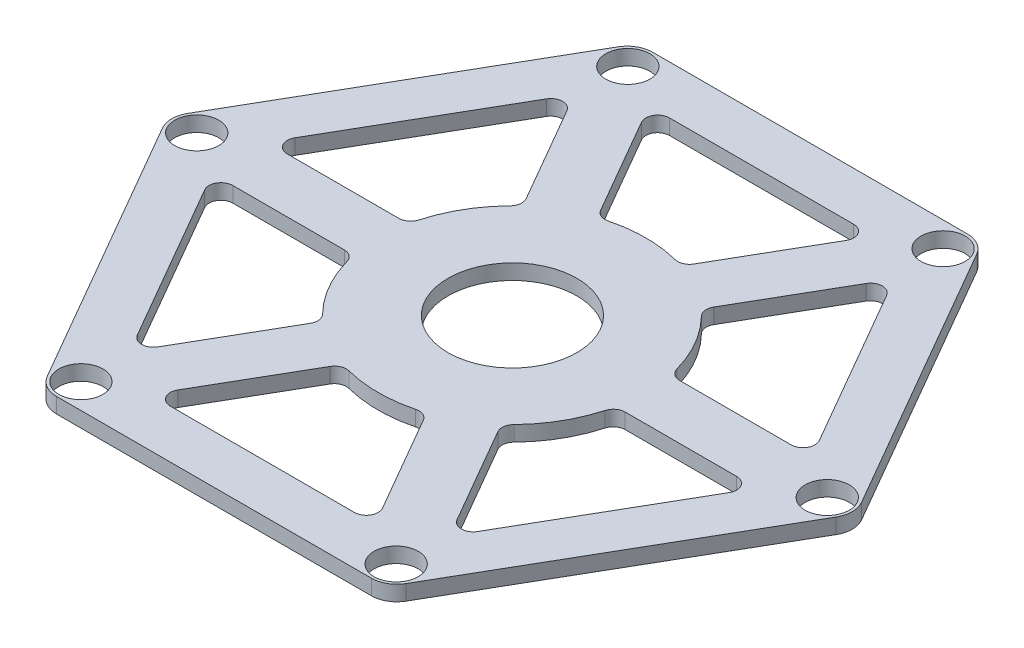
from build123d import *

# Parameters (mm, degrees)
SKETCH1_R           = 2.6
SKETCH1_R_2         = 7.6
BOSS_EXTRUDE1_DEPTH = 1.8
FILLET1_R           = 3
FILLET2_R           = 1.4
SCALE1_SCALE        = 1.15


with BuildPart() as part:
    # Sketch1 → Boss-Extrude1 (new body)
    with BuildSketch(Plane(origin=(0, 0, 0), x_dir=(1, 0, 0), z_dir=(0, 1, 0))):
        Polygon((20.3, 35.160631394), (-20.3, 35.160631394), (-40.6, 0), (-20.3, -35.160631394), (20.3, -35.160631394), (40.6, 0), align=None)
        with Locations((-18.636201283, -32.21652123)):
            Circle(SKETCH1_R, mode=Mode.SUBTRACT)
        with Locations((18.582225165, -32.247684356)):
            Circle(SKETCH1_R, mode=Mode.SUBTRACT)
        with Locations((37.218426448, -0.031163126)):
            Circle(SKETCH1_R, mode=Mode.SUBTRACT)
        with Locations((-37.218426448, 0.031163126)):
            Circle(SKETCH1_R, mode=Mode.SUBTRACT)
        with BuildLine():
            Line((-32.142053523, 3.218057696), (-18.857946477, 26.226806032))
            Line((-18.857946477, 26.226806032), (-10.521325069, 11.78735419))
            ThreePointArc((-10.521325069, 11.78735419), (-13.68320138, 7.9), (-15.468810706, 3.218057696))
            Line((-15.468810706, 3.218057696), (-32.142053523, 3.218057696))
        make_face(mode=Mode.SUBTRACT)
        with BuildLine():
            Line((-18.857946477, -26.226806032), (-32.142053523, -3.218057696))
            Line((-32.142053523, -3.218057696), (-15.468810706, -3.218057696))
            ThreePointArc((-15.468810706, -3.218057696), (-13.68320138, -7.9), (-10.521325069, -11.78735419))
            Line((-10.521325069, -11.78735419), (-18.857946477, -26.226806032))
        make_face(mode=Mode.SUBTRACT)
        with BuildLine():
            Line((13.284107046, -29.444863729), (-13.284107046, -29.444863729))
            Line((-13.284107046, -29.444863729), (-4.947485637, -15.005411886))
            ThreePointArc((-4.947485637, -15.005411886), (0, -15.8), (4.947485637, -15.005411886))
            Line((4.947485637, -15.005411886), (13.284107046, -29.444863729))
        make_face(mode=Mode.SUBTRACT)
        with BuildLine():
            Line((32.142053523, -3.218057696), (18.857946477, -26.226806032))
            Line((18.857946477, -26.226806032), (10.521325069, -11.78735419))
            ThreePointArc((10.521325069, -11.78735419), (13.68320138, -7.9), (15.468810706, -3.218057696))
            Line((15.468810706, -3.218057696), (32.142053523, -3.218057696))
        make_face(mode=Mode.SUBTRACT)
        with BuildLine():
            Line((18.857946477, 26.226806032), (32.142053523, 3.218057696))
            Line((32.142053523, 3.218057696), (15.468810706, 3.218057696))
            ThreePointArc((15.468810706, 3.218057696), (13.68320138, 7.9), (10.521325069, 11.78735419))
            Line((10.521325069, 11.78735419), (18.857946477, 26.226806032))
        make_face(mode=Mode.SUBTRACT)
        with BuildLine():
            Line((-13.284107046, 29.444863729), (13.284107046, 29.444863729))
            Line((13.284107046, 29.444863729), (4.947485637, 15.005411886))
            ThreePointArc((4.947485637, 15.005411886), (0, 15.8), (-4.947485637, 15.005411886))
            Line((-4.947485637, 15.005411886), (-13.284107046, 29.444863729))
        make_face(mode=Mode.SUBTRACT)
        with Locations((-18.582225165, 32.247684356)):
            Circle(SKETCH1_R, mode=Mode.SUBTRACT)
        with Locations((18.636201283, 32.21652123)):
            Circle(SKETCH1_R, mode=Mode.SUBTRACT)
        with Locations((0.052857117, 0)):
            Circle(SKETCH1_R_2, mode=Mode.SUBTRACT)
    extrude(amount=BOSS_EXTRUDE1_DEPTH)

    # Fillet1
    fillet1_edges = [part.edges().sort_by_distance(p)[0] for p in [
        (40.6, 0.9, 0),
        (20.3, 0.9, 35.160631394),
        (-20.3, 0.9, 35.160631394),
        (-40.6, 0.9, 0),
        (-20.3, 0.9, -35.160631394),
        (20.3, 0.9, -35.160631394),
    ]]
    fillet(fillet1_edges, radius=FILLET1_R)

    # Fillet2
    fillet2_edges = [part.edges().sort_by_distance(p)[0] for p in [
        (-32.142053523, 0.9, -3.218057696),
        (-15.468810706, 0.9, -3.218057696),
        (-10.521325069, 0.9, -11.78735419),
        (-18.857946477, 0.9, -26.226806032),
        (-18.857946477, 0.9, 26.226806032),
        (-10.521325069, 0.9, 11.78735419),
        (-15.468810706, 0.9, 3.218057696),
        (-32.142053523, 0.9, 3.218057696),
        (13.284107046, 0.9, 29.444863729),
        (4.947485637, 0.9, 15.005411886),
        (-4.947485637, 0.9, 15.005411886),
        (-13.284107046, 0.9, 29.444863729),
        (32.142053523, 0.9, 3.218057696),
        (15.468810706, 0.9, 3.218057696),
        (10.521325069, 0.9, 11.78735419),
        (18.857946477, 0.9, 26.226806032),
        (18.857946477, 0.9, -26.226806032),
        (10.521325069, 0.9, -11.78735419),
        (15.468810706, 0.9, -3.218057696),
        (32.142053523, 0.9, -3.218057696),
        (-13.284107046, 0.9, -29.444863729),
        (-4.947485637, 0.9, -15.005411886),
        (4.947485637, 0.9, -15.005411886),
        (13.284107046, 0.9, -29.444863729),
    ]]
    fillet(fillet2_edges, radius=FILLET2_R)


with BuildPart() as part_1:
    # Scale1: scaled about (-0.003928135, 0.9, 0)
    add(part.part.scale(SCALE1_SCALE).moved(Location((0.00058922, -0.135, 0))))


solid = part_1.part
